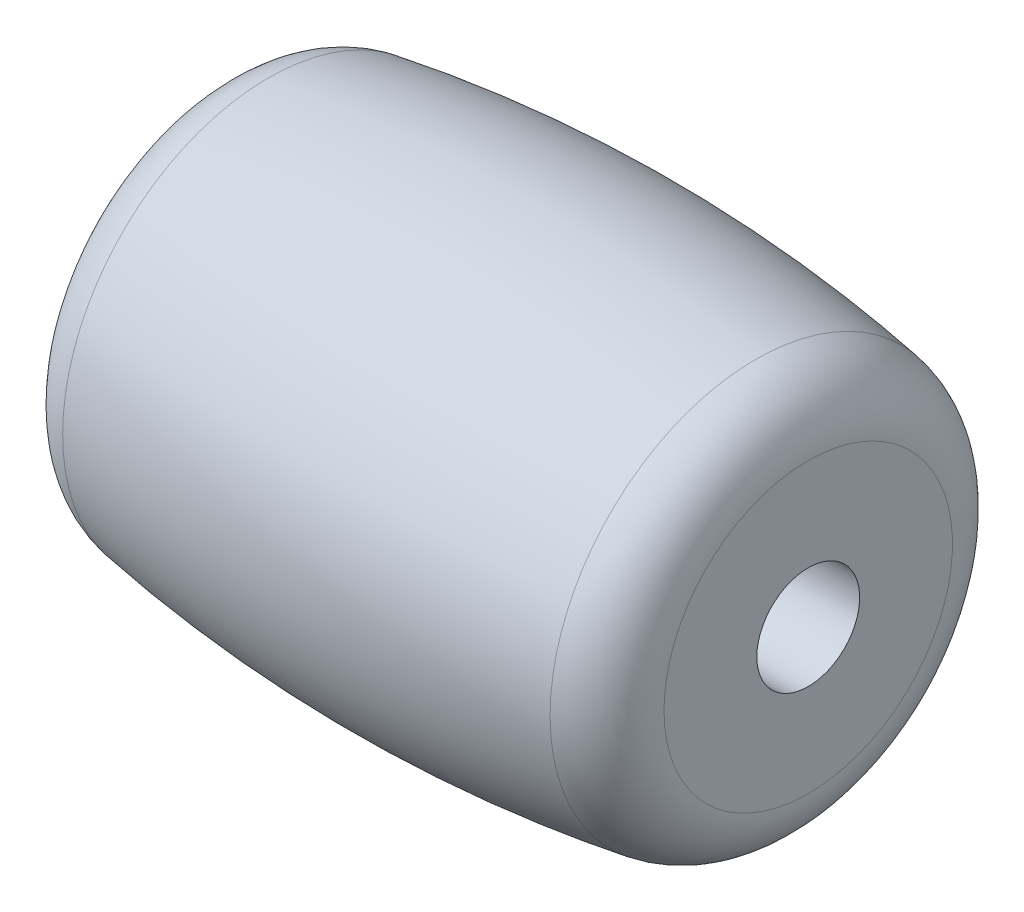
from build123d import *


with BuildPart() as part:
    # Sketch1 → Revolve1 (revolve)
    with BuildSketch(Plane(origin=(0, 0, 0), x_dir=(-1, 0, 0), z_dir=(0, 0, -1))):
        with BuildLine():
            Line((-9.5, 4.627561796), (-9.5, 1.65))
            Line((-9.5, 1.65), (9.5, 1.65))
            Line((9.5, 1.65), (9.5, 4.627561796))
            ThreePointArc((9.5, 4.627561796), (9.022905314, 5.924002849), (7.819240596, 6.601918765))
            ThreePointArc((7.819240596, 6.601918765), (0, 7.23), (-7.819240596, 6.601918765))
            ThreePointArc((-7.819240596, 6.601918765), (-9.022905314, 5.924002849), (-9.5, 4.627561796))
        make_face()
    revolve(axis=Axis((9.503089082, 0, 0), (-1, 0, 0)))


solid = part.part
